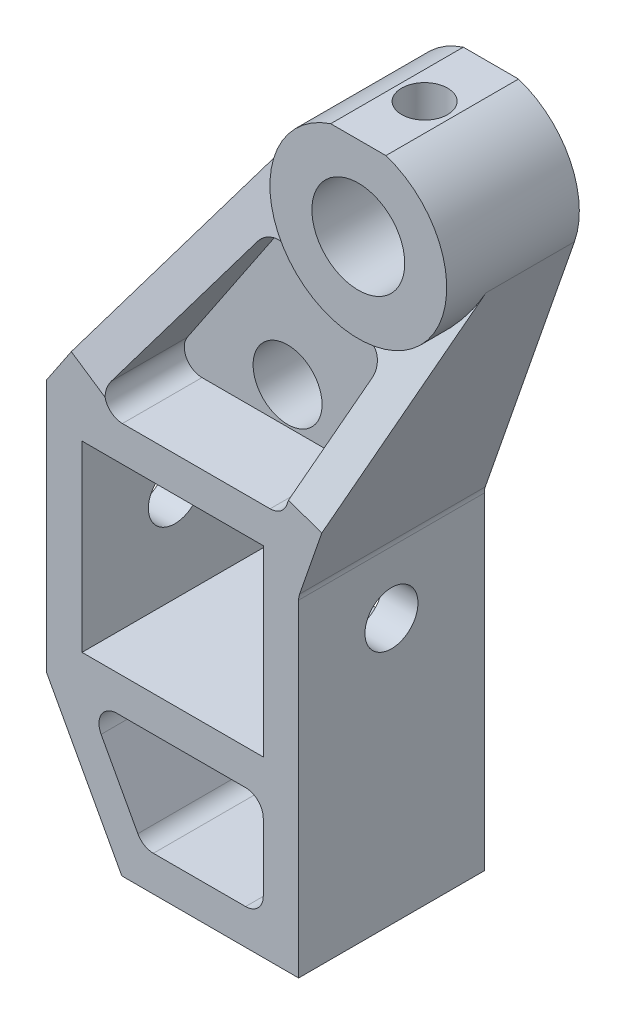
from build123d import *

# Parameters (mm, degrees)
SKETCH1_R               = 5.25
SKETCH1_R_2             = 3.9
SKETCH1_W               = 20.5
SKETCH1_H               = 20.7
BOSS_EXTRUDE1_DEPTH     = 4
SKETCH2_R               = 5.25
BOSS_EXTRUDE2_DEPTH     = 11
SKETCH3_W               = 20.5
SKETCH3_H               = 20.7
BOSS_EXTRUDE3_DEPTH     = 17
BOSS_EXTRUDE4_DEPTH     = 4
BOSS_EXTRUDE6_DEPTH     = 4
FILLET8_R               = 2
SKETCH7_R               = 2.6
CUT_EXTRUDE1_DEPTH      = 6
SKETCH9_R               = 3
CUT_EXTRUDE2_DEPTH      = 25.5
CUT_EXTRUDE2_DEPTH_BACK = 15.75
SKETCH10_R              = 3.9
BOSS_EXTRUDE7_DEPTH     = 8


with BuildPart() as part:
    # Sketch1 → Boss-Extrude1 (new body)
    with BuildSketch(Plane.XY):
        with BuildLine():
            Line((-29.25, -25.65), (-29.25, -54.35))
            Line((-29.25, -54.35), (-20.75, -70))
            Line((-20.75, -70), (-0.75, -70))
            Line((-0.75, -70), (-0.75, -32.65))
            Line((-0.75, -32.65), (9.446850202, -3.279789821))
            ThreePointArc((9.446850202, -3.279789821), (8.962582875, 4.435325039), (3.122498999, 9.5))
            Line((3.122498999, 9.5), (-3.122498999, 9.5))
            ThreePointArc((-3.122498999, 9.5), (-6.041680661, 7.968569181), (-8.304318811, 5.571201763))
            Line((-8.304318811, 5.571201763), (-29.25, -25.65))
        make_face()
        Circle(SKETCH1_R, mode=Mode.SUBTRACT)
        with Locations((-11, -21.5)):
            Circle(SKETCH1_R_2, mode=Mode.SUBTRACT)
        with Locations((-15, -40)):
            Rectangle(SKETCH1_W, SKETCH1_H, mode=Mode.SUBTRACT)
    extrude(amount=BOSS_EXTRUDE1_DEPTH)

    # Sketch2 → Boss-Extrude2 (add)
    with BuildSketch(Plane.XY.offset(4)):
        with BuildLine():
            Line((3.122498999, 9.5), (-3.122498999, 9.5))
            ThreePointArc((-3.122498999, 9.5), (0, -10), (3.122498999, 9.5))
        make_face()
        Circle(SKETCH2_R, mode=Mode.SUBTRACT)
    extrude(amount=BOSS_EXTRUDE2_DEPTH)

    # Sketch3 → Boss-Extrude3 (add)
    with BuildSketch(Plane.XY.offset(4)):
        Polygon((-29.25, -25.65), (-29.25, -54.35), (-20.75, -70), (-0.75, -70), (-0.75, -25.65), align=None)
        with Locations((-15, -40)):
            Rectangle(SKETCH3_W, SKETCH3_H, mode=Mode.SUBTRACT)
        with BuildLine():
            Line((-6.75, -54.35), (-21.33587702, -54.35))
            ThreePointArc((-21.33587702, -54.35), (-23.054759053, -55.327530168), (-23.093382043, -57.304555444))
            Line((-23.093382043, -57.304555444), (-18.938429966, -64.954555444))
            ThreePointArc((-18.938429966, -64.954555444), (-18.203394775, -65.718882033), (-17.180924944, -66))
            Line((-17.180924944, -66), (-6.75, -66))
            ThreePointArc((-6.75, -66), (-5.335786438, -65.414213562), (-4.75, -64))
            Line((-4.75, -64), (-4.75, -56.35))
            ThreePointArc((-4.75, -56.35), (-5.335786438, -54.935786438), (-6.75, -54.35))
        make_face(mode=Mode.SUBTRACT)
    extrude(amount=BOSS_EXTRUDE3_DEPTH)

    # Sketch4 → Boss-Extrude4 (add)
    with BuildSketch(Plane(origin=(-8.304318811, 5.571201763, 0), x_dir=(0, 0, 1), z_dir=(-0.830431881, 0.557120176, 0))):
        Polygon((4, -37.596342907), (21, -37.596342907), (21, -32.596342907), (12, 0), (4, 0), align=None)
    extrude(amount=-BOSS_EXTRUDE4_DEPTH)

    # Sketch6 → Boss-Extrude6 (add)
    with BuildSketch(Plane(origin=(9.446850202, -3.279789821, 0), x_dir=(0, 0, -1), z_dir=(0.94468502, -0.327978982, 0))):
        Polygon((-4, -31.089950145), (-21, -31.089950145), (-21, -23.089950145), (-10, 0), (-4, 0), align=None)
    extrude(amount=-BOSS_EXTRUDE6_DEPTH)

    # Fillet8
    fillet8_edges = [part.edges().sort_by_distance(p)[0] for p in [
        (-24.433229244, -25.65, 12.5),
        (-2.553931563, -25.65, 12.5),
        (3.044278264, -9.525354054, 8.905590949),
        (-9.439552697, -3.300733991, 9.104418373),
        (-0.75, -32.65, 10.5),
    ]]
    fillet(fillet8_edges, radius=FILLET8_R)

    # Sketch7 → Cut-Extrude1 (cut)
    with BuildSketch(Plane(origin=(0, 9.5, 0), x_dir=(1, 0, 0), z_dir=(0, 1, 0))):
        with Locations(Location((0, -7.5, 0), (0, 0, 270))):  # turned: the seam where the file's is
            Circle(SKETCH7_R)
    extrude(amount=-CUT_EXTRUDE1_DEPTH, mode=Mode.SUBTRACT)

    # Sketch9 → Cut-Extrude2 (cut, two sides)
    with BuildSketch(Plane.ZY.offset(4.75)) as cut_extrude2_sk:
        with Locations(Location((10.5, -40, 0), (0, 0, 270))):  # turned: the seam where the file's is
            Circle(SKETCH9_R)
    extrude(amount=CUT_EXTRUDE2_DEPTH, mode=Mode.SUBTRACT)
    extrude(cut_extrude2_sk.sketch, amount=-CUT_EXTRUDE2_DEPTH_BACK, mode=Mode.SUBTRACT)

    # Sketch10 → Boss-Extrude7 (add)
    with BuildSketch(Plane.XY.offset(4)):
        with BuildLine():
            Line((-11.28568656, -6.052543173), (-22.343947541, -22.535759647))
            ThreePointArc((-22.343947541, -22.535759647), (-22.44780482, -24.591148048), (-20.683083779, -25.65))
            Line((-20.683083779, -25.65), (-3.976672485, -25.65))
            ThreePointArc((-3.976672485, -25.65), (-2.817344215, -25.279711006), (-2.087302444, -24.305957964))
            Line((-2.087302444, -24.305957964), (1.957451524, -12.655764834))
            ThreePointArc((1.957451524, -12.655764834), (1.69449722, -10.835860199), (0.05673457, -9.999839058))
            ThreePointArc((0.05673457, -9.999839058), (-4.462214417, -8.949225805), (-8.020685665, -5.972319605))
            ThreePointArc((-8.020685665, -5.972319605), (-9.6739495, -5.167386975), (-11.28568656, -6.052543173))
        make_face()
        with Locations((-11, -21.5)):
            Circle(SKETCH10_R, mode=Mode.SUBTRACT)
    extrude(amount=BOSS_EXTRUDE7_DEPTH)


solid = part.part
